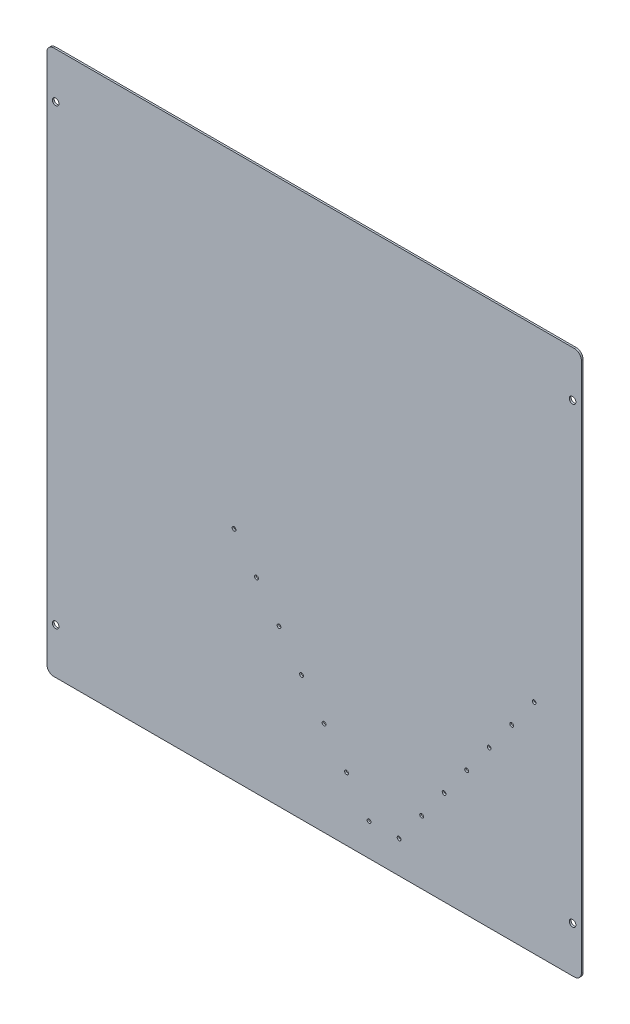
from build123d import *

# Parameters (mm, degrees)
BOSS_EXTRUDE1_DEPTH             = 1.5875
A_0_234_DIAMETER_HOLE1_D        = 5.9436
A_0_234_DIAMETER_HOLE1_DEPTH    = 6.35
A_0_234_DIAMETER_HOLE1_TIP      = 1.785637588
F_29_0_136_DIAMETER_HOLE1_D     = 3.4544
F_29_0_136_DIAMETER_HOLE1_DEPTH = 19.05
F_29_0_136_DIAMETER_HOLE1_TIP   = 1.037806461


with BuildPart() as part:
    # Sketch1 → Boss-Extrude1 (new body)
    with BuildSketch(Plane.XY):
        with BuildLine():
            Line((6.35, 0), (476.25, 0))
            ThreePointArc((476.25, 0), (480.740128061, 1.859871939), (482.6, 6.35))
            Line((482.6, 6.35), (482.6, 485.14))
            ThreePointArc((482.6, 485.14), (480.740128061, 489.630128061), (476.25, 491.49))
            Line((476.25, 491.49), (6.35, 491.49))
            ThreePointArc((6.35, 491.49), (1.859871939, 489.630128061), (0, 485.14))
            Line((0, 485.14), (0, 6.35))
            ThreePointArc((0, 6.35), (1.859871939, 1.859871939), (6.35, 0))
        make_face()
    extrude(amount=-BOSS_EXTRUDE1_DEPTH)

    # A (0.234) Diameter Hole1
    with Locations(Plane(origin=(-396.999136144, -1211.173521534, 0), x_dir=(1, 0, 0), z_dir=(0, 0, 1))):
        with Locations((871.661631208, 1252.447991883), (871.661636144, 1661.387931308), (404.936636144, 1661.388521534), (404.936631208, 1252.447991883)):
            Hole(A_0_234_DIAMETER_HOLE1_D / 2, depth=A_0_234_DIAMETER_HOLE1_DEPTH)
            with Locations((0, 0, -(A_0_234_DIAMETER_HOLE1_DEPTH + A_0_234_DIAMETER_HOLE1_TIP / 2))):  # 118° drill point
                Cone(0, A_0_234_DIAMETER_HOLE1_D / 2, A_0_234_DIAMETER_HOLE1_TIP, mode=Mode.SUBTRACT)

    # #29 (0.136) Diameter Hole1
    with Locations(Plane(origin=(-437.078957849, -1254.719045707, 0), x_dir=(1, 0, 0), z_dir=(0, 0, 1))):
        with Locations((606.067697849, 1451.569045707), (626.387697849, 1423.629045707), (646.707697849, 1395.689045707), (667.027697849, 1367.749045707), (687.347697849, 1339.809045707), (707.667697849, 1311.869045707), (727.987697849, 1283.929045707), (755.133947849, 1283.929045707), (775.453947849, 1311.869045707), (795.773947849, 1339.809045707), (816.093947849, 1367.749045707), (877.053947849, 1451.569045707), (856.733947849, 1423.629045707), (836.413947849, 1395.689045707)):
            Hole(F_29_0_136_DIAMETER_HOLE1_D / 2, depth=F_29_0_136_DIAMETER_HOLE1_DEPTH)
            with Locations((0, 0, -(F_29_0_136_DIAMETER_HOLE1_DEPTH + F_29_0_136_DIAMETER_HOLE1_TIP / 2))):  # 118° drill point
                Cone(0, F_29_0_136_DIAMETER_HOLE1_D / 2, F_29_0_136_DIAMETER_HOLE1_TIP, mode=Mode.SUBTRACT)


solid = part.part
